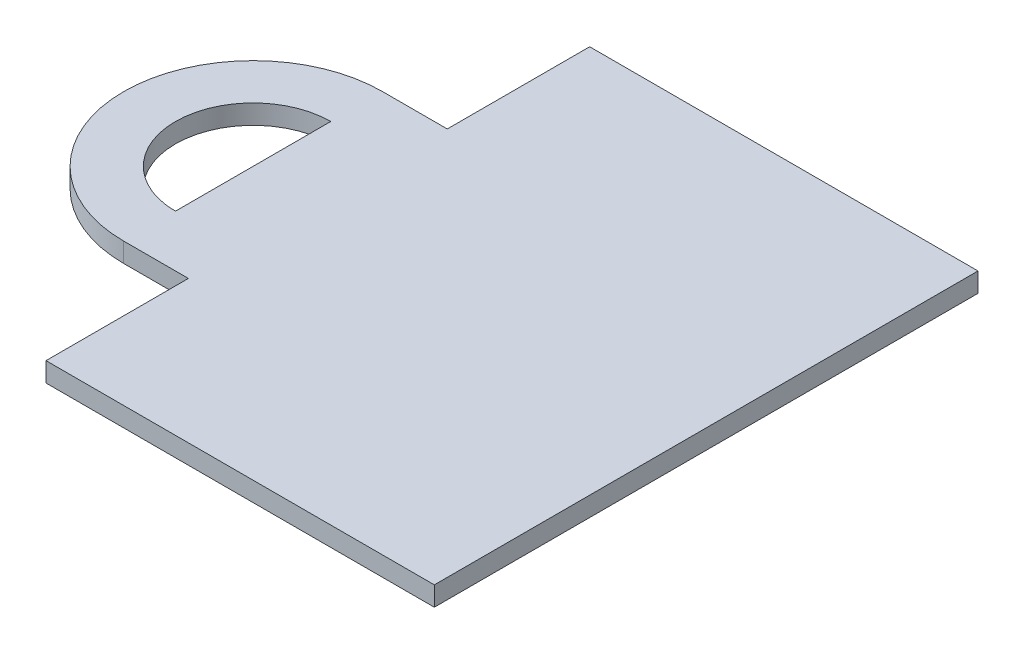
from build123d import *

# Parameters (mm, degrees)
BOSS_EXTRUDE1_DEPTH = 7.5


with BuildPart() as part:
    # Sketch1 → Boss-Extrude1 (new body)
    with BuildSketch(Plane(origin=(0, 0, 0), x_dir=(1, 0, 0), z_dir=(0, 1, 0))):
        with BuildLine():
            Line((0, 0), (-150, 0))
            Line((-150, 0), (-150, -55))
            Line((-150, -55), (-175, -55))
            ThreePointArc((-175, -55), (-225, -105), (-175, -155))
            Line((-175, -155), (-150, -155))
            Line((-150, -155), (-150, -210))
            Line((-150, -210), (0, -210))
            Line((0, -210), (0, 0))
        make_face()
        with BuildLine():
            Line((-175, -75), (-175, -135))
            ThreePointArc((-175, -135), (-205, -105), (-175, -75))
        make_face(mode=Mode.SUBTRACT)
    extrude(amount=BOSS_EXTRUDE1_DEPTH)


solid = part.part
